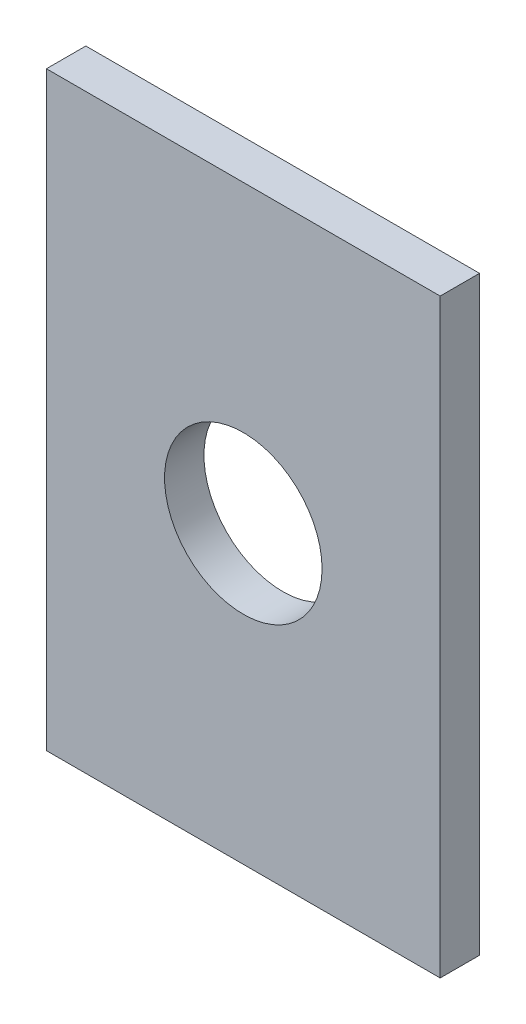
from build123d import *

# Parameters (mm, degrees)
SZKIC1_W                    = 20
SZKIC1_H                    = 30
SZKIC1_R                    = 4
DODANIE_WYCI_GNI_CIE1_DEPTH = 2


with BuildPart() as part:
    # Szkic1 → Dodanie-wyciągnięcie1 (new body)
    with BuildSketch(Plane.XY):
        with Locations((10, 15)):
            Rectangle(SZKIC1_W, SZKIC1_H)
        with Locations((10, 15)):
            Circle(SZKIC1_R, mode=Mode.SUBTRACT)
    extrude(amount=DODANIE_WYCI_GNI_CIE1_DEPTH)


solid = part.part
